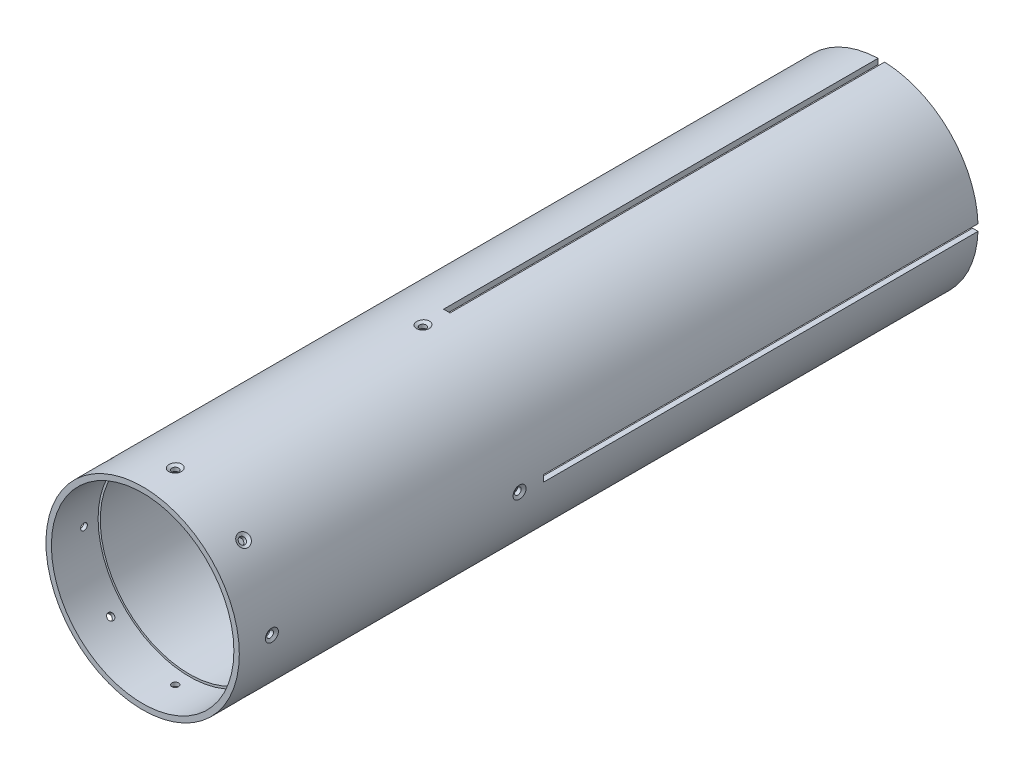
from build123d import *

# Parameters (mm, degrees)
ESQUISSE1_R                  = 44.5
BOSS_EXTRU_1_DEPTH           = 340
ESQUISSE2_R                  = 42
ENL_V_MAT_EXTRU_1_DEPTH      = 1150
ESQUISSE3_W                  = 10
ESQUISSE3_H                  = 3
ENL_V_MAT_EXTRU_2_DEPTH      = 200
D_GAGEMENT_M2_51_AT_2_COUNT  = 2
D_GAGEMENT_M2_51_AT_2_PITCH  = 219.405790112
R_P_TITION_CIRCULAIRE1_COUNT = 4
D_GAGEMENT_M2_52_D           = 3.1
D_GAGEMENT_M2_52_CSINK_D     = 6
D_GAGEMENT_M2_52_CSINK_ANGLE = 120
R_P_TITION_CIRCULAIRE2_COUNT = 8
ESQUISSE7_W                  = 1
ESQUISSE7_H                  = 98.5


with BuildPart() as part:
    # Esquisse1 → Boss.-Extru.1 (new body)
    with BuildSketch(Plane.XY):
        Circle(ESQUISSE1_R)
    extrude(amount=BOSS_EXTRU_1_DEPTH)

    # Esquisse2 → Enlèv. mat.-Extru.1 (cut)
    with BuildSketch(Plane(origin=(0, 0, 0), x_dir=(-1, 0, 0), z_dir=(0, 0, -1))):
        Circle(ESQUISSE2_R)
    extrude(amount=-ENL_V_MAT_EXTRU_1_DEPTH, mode=Mode.SUBTRACT)

    # Esquisse3 → Enlèv. mat.-Extru.2 (cut)
    with BuildSketch(Plane.XY):
        with Locations((-45, 0)):
            Rectangle(ESQUISSE3_W, ESQUISSE3_H)
    enl_v_mat_extru_2 = extrude(amount=ENL_V_MAT_EXTRU_2_DEPTH, mode=Mode.SUBTRACT)

    # Esquisse5 → Dégagement M2.51 (revolve, cut)
    with BuildSketch(Plane(origin=(-44.5, 0, 211), x_dir=(0, 0, 1), z_dir=(0, 1, 0))):
        Polygon((0, 0), (0, 15.931333959), (1.55, 15), (1.55, 0.83715789), (3, 0), align=None)
    d_gagement_m2_51 = revolve(axis=Axis((-50.85, 0, 211), (1, 0, 0)), mode=Mode.SUBTRACT)

    # Dégagement M2.51 at 2: Dégagement M2.51 ×2
    with Locations(*[Vector(0, -0.274144943, -0.961688385) * (i * D_GAGEMENT_M2_51_AT_2_PITCH) for i in range(1, D_GAGEMENT_M2_51_AT_2_COUNT)]):
        add(d_gagement_m2_51, mode=Mode.SUBTRACT)

    # Répétition circulaire1: Dégagement M2.51, Enlèv. mat.-Extru.2 ×4 about axis
    r_p_tition_circulaire1_axis = Axis((0, 0, 0), (0, 0, 1))
    for i in range(1, R_P_TITION_CIRCULAIRE1_COUNT):
        add(d_gagement_m2_51.rotate(r_p_tition_circulaire1_axis, i * 360 / R_P_TITION_CIRCULAIRE1_COUNT), mode=Mode.SUBTRACT)
        add(enl_v_mat_extru_2.rotate(r_p_tition_circulaire1_axis, i * 360 / R_P_TITION_CIRCULAIRE1_COUNT), mode=Mode.SUBTRACT)

    # Répétition circulaire1 copy 1 sketch → Répétition circulaire1 copy 1 (revolve, cut)
    with BuildSketch(Plane(origin=(60.14898781, -44.5, 0), x_dir=(0, 0, 1), z_dir=(-1, 0, 0))):
        Polygon((0, 0), (0, 15.931333959), (1.55, 15), (1.55, 0.83715789), (3, 0), align=None)
    revolve(axis=Axis((60.14898781, -50.85, 0), (0, 1, 0)), mode=Mode.SUBTRACT)

    # Répétition circulaire1 copy 2 sketch → Répétition circulaire1 copy 2 (revolve, cut)
    with BuildSketch(Plane(origin=(44.5, 60.14898781, 0), x_dir=(0, 0, 1), z_dir=(0, -1, 0))):
        Polygon((0, 0), (0, 15.931333959), (1.55, 15), (1.55, 0.83715789), (3, 0), align=None)
    revolve(axis=Axis((50.85, 60.14898781, 0), (-1, 0, 0)), mode=Mode.SUBTRACT)

    # Répétition circulaire1 copy 3 sketch → Répétition circulaire1 copy 3 (revolve, cut)
    with BuildSketch(Plane(origin=(-60.14898781, 44.5, 0), x_dir=(0, 0, 1), z_dir=(1, 0, 0))):
        Polygon((0, 0), (0, 15.931333959), (1.55, 15), (1.55, 0.83715789), (3, 0), align=None)
    revolve(axis=Axis((-60.14898781, 50.85, 0), (0, -1, 0)), mode=Mode.SUBTRACT)

    # Dégagement M2.52 (through all)
    with Locations(Plane(origin=(44.5, 0, 325), x_dir=(0, 1, 0), z_dir=(1, 0, 0))):
        with Locations((0, 0)):
            d_gagement_m2_52 = CounterSinkHole(D_GAGEMENT_M2_52_D / 2, D_GAGEMENT_M2_52_CSINK_D / 2, counter_sink_angle=D_GAGEMENT_M2_52_CSINK_ANGLE)

    # Répétition circulaire2: Dégagement M2.52 ×8 about axis
    r_p_tition_circulaire2_axis = Axis((0, 0, 340), (0, 0, 1))
    for i in range(1, R_P_TITION_CIRCULAIRE2_COUNT):
        add(d_gagement_m2_52.rotate(r_p_tition_circulaire2_axis, i * 360 / R_P_TITION_CIRCULAIRE2_COUNT), mode=Mode.SUBTRACT)

    # Esquisse7 → Révolution1 (revolve)
    with BuildSketch(Plane(origin=(0, 0, 0), x_dir=(1, 0, 0), z_dir=(0, 1, 0))):
        with Locations((41.5, -269.25)):
            Rectangle(ESQUISSE7_W, ESQUISSE7_H)
    revolve(axis=Axis((0, 0, 353.091886685), (0, 0, -1)))


solid = part.part
